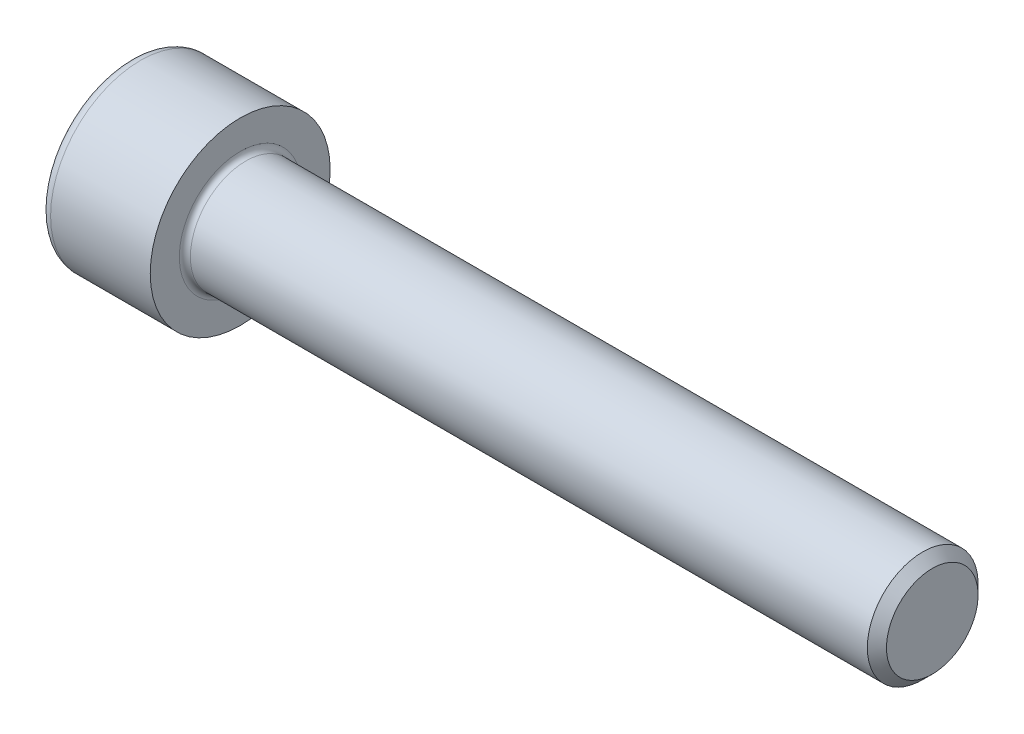
from build123d import *

# Parameters (mm, degrees)
FILLET1_R   = 0.4
FILLET2_R   = 0.8
HEX_2_DEPTH = 4


with BuildPart() as part:
    # BodySke → Base-Revolve (revolve)
    with BuildSketch(Plane.XY):
        Polygon((0, 0), (0, 6.5), (8, 6.5), (8, 4), (57.3095, 4), (58, 3.3095), (58, 0), align=None)
    revolve(axis=Axis((-31.75, 0, 0), (1, 0, 0)))

    # Fillet1
    fillet1_edges = [part.edges().sort_by_distance(p)[0] for p in [
        (8, -4, 0),
    ]]
    fillet(fillet1_edges, radius=FILLET1_R)

    # Fillet2
    fillet2_edges = [part.edges().sort_by_distance(p)[0] for p in [
        (0, -6.5, 0),
    ]]
    fillet(fillet2_edges, radius=FILLET2_R)

    # Sketch2 → Hex-PreBroach (revolve, cut)
    with BuildSketch(Plane.XY):
        Polygon((0, 3.01), (4, 3.01), (5.73782431, 0), (0, 0), align=None)
    revolve(axis=Axis((0, 0, 0), (1, 0, 0)), mode=Mode.SUBTRACT)

    # Sketch3 → Hex 2 (cut)
    with BuildSketch(Plane(origin=(0, 0, 0), x_dir=(0, 0.5, 0.866025404), z_dir=(-1, 0, 0))):
        Polygon((1.73782431, 3.01), (-1.73782431, 3.01), (-3.475648621, 0), (-1.73782431, -3.01), (1.73782431, -3.01), (3.475648621, 0), align=None)
    extrude(amount=-HEX_2_DEPTH, mode=Mode.SUBTRACT)


solid = part.part
